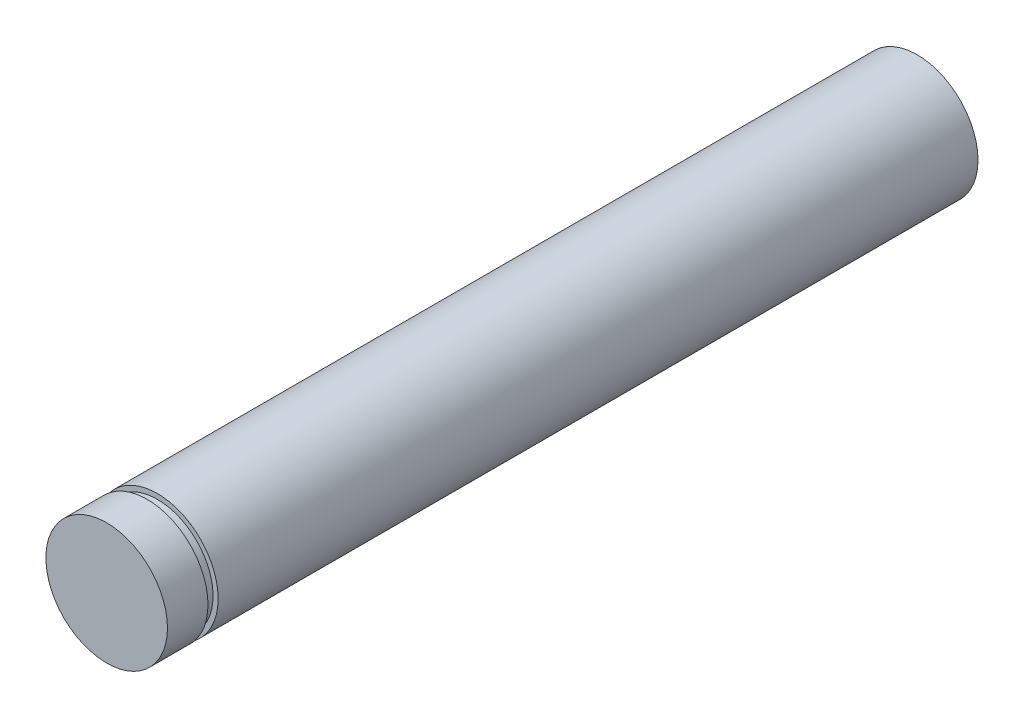
from build123d import *

# Parameters (mm, degrees)
SKETCH_1_R           = 6
EXTRUDE_1_DEPTH      = 70
EXTRUDE_1_DEPTH_BACK = 10
SKETCH_3_W           = 1
SKETCH_3_H           = 0.5


with BuildPart() as part:
    # 草图1 → 凸台-拉伸1 (new body, two sides)
    with BuildSketch(Plane.XY) as extrude_1_sk:
        Circle(SKETCH_1_R)
    extrude(amount=EXTRUDE_1_DEPTH)
    extrude(extrude_1_sk.sketch, amount=-EXTRUDE_1_DEPTH_BACK)

    # 草图3 → 切除-旋转1 (revolve, cut)
    with BuildSketch(Plane(origin=(0, 0, 0), x_dir=(0, 0, -1), z_dir=(1, 0, 0))):
        with Locations((-65.5, 5.75)):
            Rectangle(SKETCH_3_W, SKETCH_3_H)
    revolve(axis=Axis((0, 0, 70), (0, 0, -1)), mode=Mode.SUBTRACT)


solid = part.part
